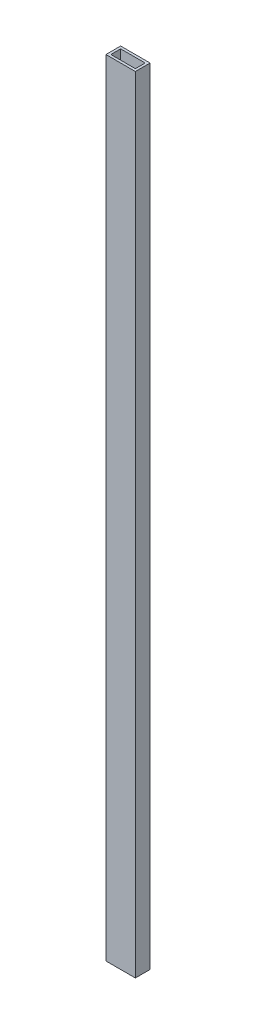
from build123d import *

# Parameters (mm, degrees)
SKETCH1_W           = 38.1
SKETCH1_H           = 19.05
SKETCH1_W_2         = 31.75
SKETCH1_H_2         = 12.7
BOSS_EXTRUDE1_DEPTH = 1016


with BuildPart() as part:
    # Sketch1 → Boss-Extrude1 (new body)
    with BuildSketch(Plane(origin=(0, 0, 0), x_dir=(1, 0, 0), z_dir=(0, 1, 0))):
        with Locations((19.05, 9.525)):
            Rectangle(SKETCH1_W, SKETCH1_H)
        with Locations((19.05, 9.525)):
            Rectangle(SKETCH1_W_2, SKETCH1_H_2, mode=Mode.SUBTRACT)
    extrude(amount=BOSS_EXTRUDE1_DEPTH)


solid = part.part
